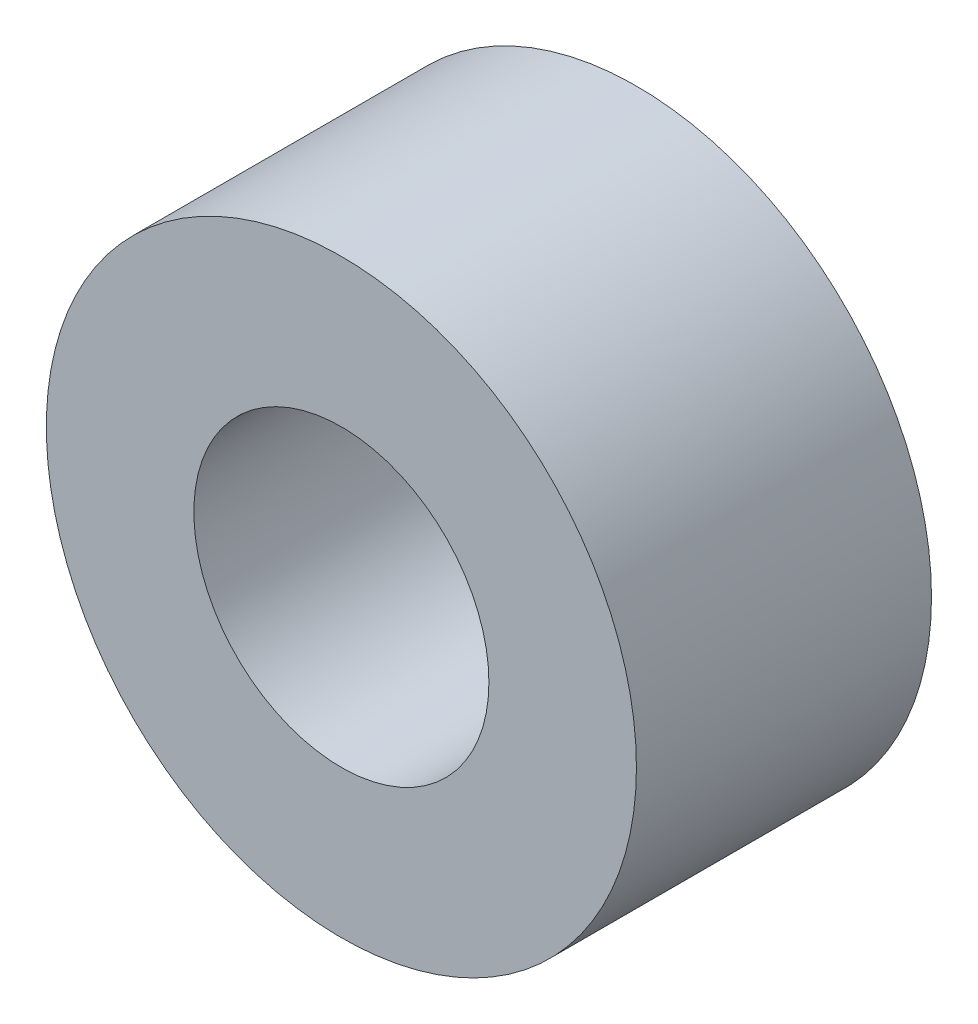
from build123d import *

# Parameters (mm, degrees)
SKETCH1_R           = 3
SKETCH1_R_2         = 1.5
BOSS_EXTRUDE1_DEPTH = 1.5


with BuildPart() as part:
    # Sketch1 → Boss-Extrude1 (new body, symmetric)
    with BuildSketch(Plane.XY):
        Circle(SKETCH1_R)
        Circle(SKETCH1_R_2, mode=Mode.SUBTRACT)
    extrude(amount=BOSS_EXTRUDE1_DEPTH, both=True)


solid = part.part
